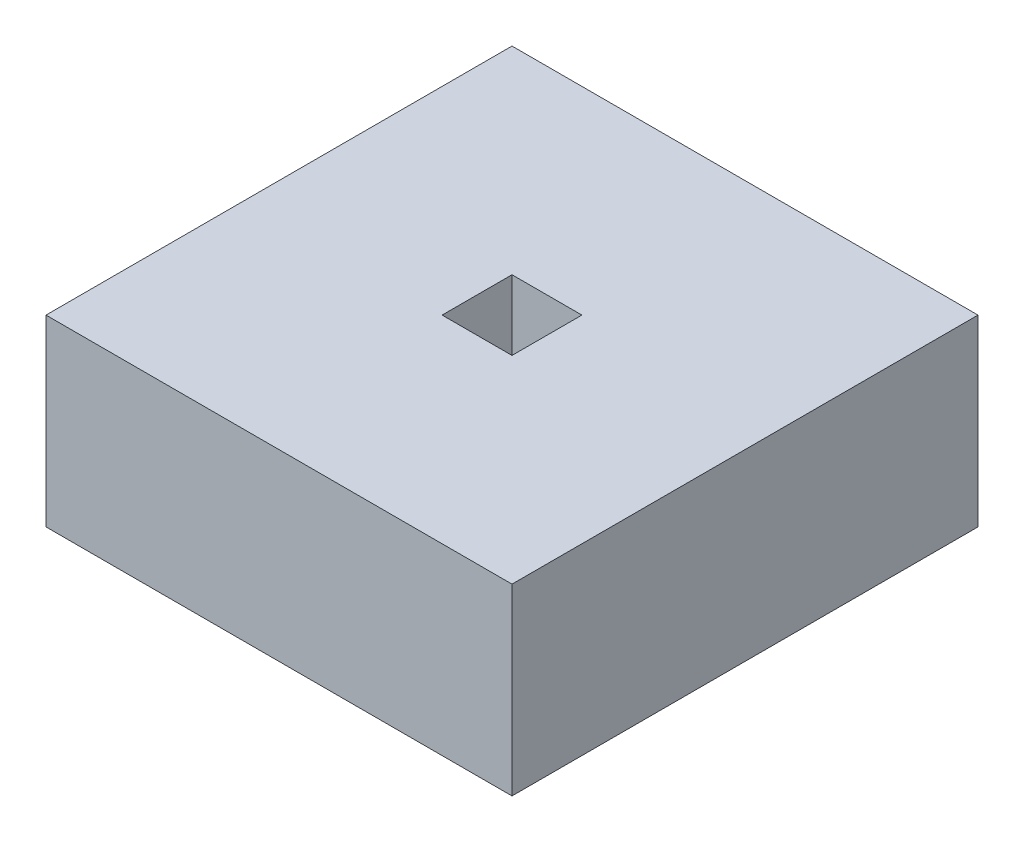
from build123d import *

# Parameters (mm, degrees)
SKETCH1_W           = 254
SKETCH1_H           = 254
SKETCH1_W_2         = 38.1
SKETCH1_H_2         = 38.1
BOSS_EXTRUDE1_DEPTH = 100
SKETCH2_W           = 252
SKETCH2_H           = 252
SKETCH2_W_2         = 40.1
SKETCH2_H_2         = 40.1
CUT_EXTRUDE1_DEPTH  = 98


with BuildPart() as part:
    # Sketch1 → Boss-Extrude1 (new body)
    with BuildSketch(Plane(origin=(0, 0, 0), x_dir=(1, 0, 0), z_dir=(0, 1, 0))):
        Rectangle(SKETCH1_W, SKETCH1_H)
        Rectangle(SKETCH1_W_2, SKETCH1_H_2, mode=Mode.SUBTRACT)
    extrude(amount=BOSS_EXTRUDE1_DEPTH)

    # Sketch2 → Cut-Extrude1 (cut)
    with BuildSketch(Plane(origin=(0, 99, 0), x_dir=(1, 0, 0), z_dir=(0, 1, 0))):
        Rectangle(SKETCH2_W, SKETCH2_H)
        Rectangle(SKETCH2_W_2, SKETCH2_H_2, mode=Mode.SUBTRACT)
    extrude(amount=-CUT_EXTRUDE1_DEPTH, mode=Mode.SUBTRACT)


solid = part.part
